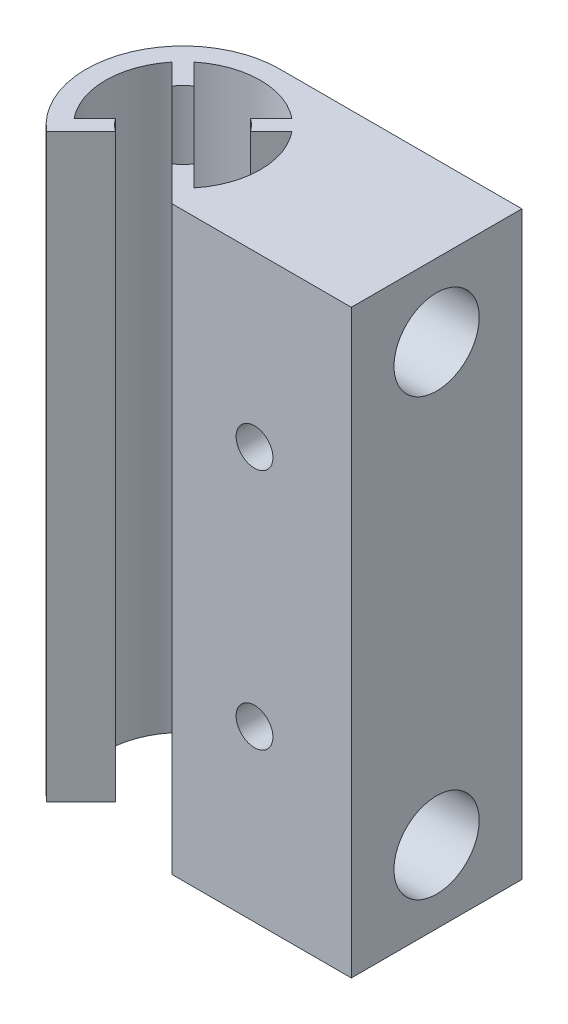
from build123d import *

# Parameters (mm, degrees)
BOSS_EXTRUDE1_DEPTH = 60
CUT_EXTRUDE2_REACH  = 19.614
SKETCH3_R           = 1.9
SKETCH4_R           = 4.4
CUT_EXTRUDE3_DEPTH  = 10


with BuildPart() as part:
    # Sketch1 → Boss-Extrude1 (new body)
    with BuildSketch(Plane(origin=(0, 0, 0), x_dir=(1, 0, 0), z_dir=(0, 1, 0))):
        with BuildLine():
            Line((0, 10), (-10, 10))
            ThreePointArc((-10, 10), (-19.384585633, 3.453918427), (-16.48271865, -7.6140895))
            Line((-16.48271865, -7.6140895), (-12.924300248, -4.055671098))
            ThreePointArc((-12.924300248, -4.055671098), (-13.535533906, -3.535533906), (-14.055671098, -2.924300248))
            Line((-14.055671098, -2.924300248), (-16.194184337, -5.062813487))
            ThreePointArc((-16.194184337, -5.062813487), (-18, 0), (-16.194184337, 5.062813487))
            Line((-16.194184337, 5.062813487), (-14.055671098, 2.924300248))
            ThreePointArc((-14.055671098, 2.924300248), (-13.535533906, 3.535533906), (-12.924300248, 4.055671098))
            Line((-12.924300248, 4.055671098), (-15.062813487, 6.194184337))
            ThreePointArc((-15.062813487, 6.194184337), (-10, 8), (-4.937186513, 6.194184337))
            Line((-4.937186513, 6.194184337), (-7.075699752, 4.055671098))
            ThreePointArc((-7.075699752, 4.055671098), (-6.464466094, 3.535533906), (-5.944328902, 2.924300248))
            Line((-5.944328902, 2.924300248), (-3.805815663, 5.062813487))
            ThreePointArc((-3.805815663, 5.062813487), (-2, 0), (-3.805815663, -5.062813487))
            Line((-3.805815663, -5.062813487), (-5.944328902, -2.924300248))
            ThreePointArc((-5.944328902, -2.924300248), (-6.464466094, -3.535533906), (-7.075699752, -4.055671098))
            Line((-7.075699752, -4.055671098), (-3.51728135, -7.6140895))
            Line((-3.51728135, -7.6140895), (15, -7.6140895))
            Line((15, -7.6140895), (15, 1.19295525))
            Line((15, 1.19295525), (15, 10))
            Line((15, 10), (0, 10))
        make_face()
    extrude(amount=BOSS_EXTRUDE1_DEPTH)

    # Sketch3 → Cut-Extrude2 (cut, up to next)
    with BuildSketch(Plane(origin=(0, 0, -10), x_dir=(-1, 0, 0), z_dir=(0, 0, -1)), mode=Mode.PRIVATE) as cut_extrude2_sk1:
        with Locations((-5, 42.5)):
            Circle(SKETCH3_R)
    cut_extrude2_tool1 = extrude(cut_extrude2_sk1.sketch, amount=-CUT_EXTRUDE2_REACH, mode=Mode.PRIVATE) & part.part
    add(cut_extrude2_tool1.solids().sort_by_distance((5, 42.5, -10))[0], mode=Mode.SUBTRACT)
    # Sketch3 → Cut-Extrude2 (cut, up to next)
    with BuildSketch(Plane(origin=(0, 0, -10), x_dir=(-1, 0, 0), z_dir=(0, 0, -1)), mode=Mode.PRIVATE) as cut_extrude2_sk2:
        with Locations((-5, 17.5)):
            Circle(SKETCH3_R)
    cut_extrude2_tool2 = extrude(cut_extrude2_sk2.sketch, amount=-CUT_EXTRUDE2_REACH, mode=Mode.PRIVATE) & part.part
    add(cut_extrude2_tool2.solids().sort_by_distance((5, 17.5, -10))[0], mode=Mode.SUBTRACT)

    # Sketch4 → Cut-Extrude3 (cut)
    with BuildSketch(Plane(origin=(15, 0, 0), x_dir=(0, 0, -1), z_dir=(1, 0, 0))):
        with Locations((1.19295525, 7.5)):
            Circle(SKETCH4_R)
        with Locations((1.19295525, 52.5)):
            Circle(SKETCH4_R)
    extrude(amount=-CUT_EXTRUDE3_DEPTH, mode=Mode.SUBTRACT)


solid = part.part
